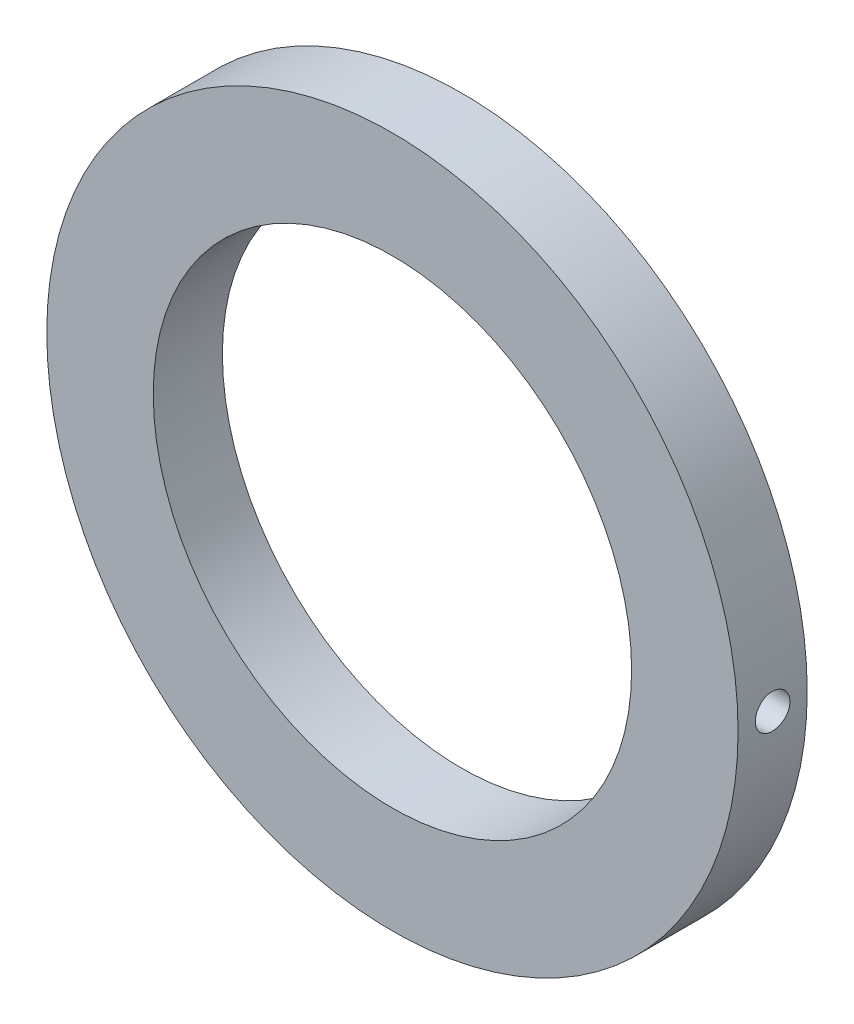
from build123d import *

# Parameters (mm, degrees)
ESBO_O1_R                = 25
ESBO_O1_R_2              = 17.3
RESSALTO_EXTRUS_O1_DEPTH = 5
ESBO_O2_W                = 1.25
ESBO_O2_H                = 25


with BuildPart() as part:
    # Esboço1 → Ressalto-extrusão1 (new body)
    with BuildSketch(Plane.XY):
        Circle(ESBO_O1_R)
        Circle(ESBO_O1_R_2, mode=Mode.SUBTRACT)
    extrude(amount=RESSALTO_EXTRUS_O1_DEPTH)

    # Esboço2 → Furo roscado de M3x0.51 (revolve, cut)
    with BuildSketch(Plane(origin=(0, 0, 2.5), x_dir=(0, 0, 1), z_dir=(0, 1, 0))):
        with Locations((0.625, 12.5)):
            Rectangle(ESBO_O2_W, ESBO_O2_H)
    revolve(axis=Axis((-6.35, 0, 2.5), (1, 0, 0)), mode=Mode.SUBTRACT)


solid = part.part
